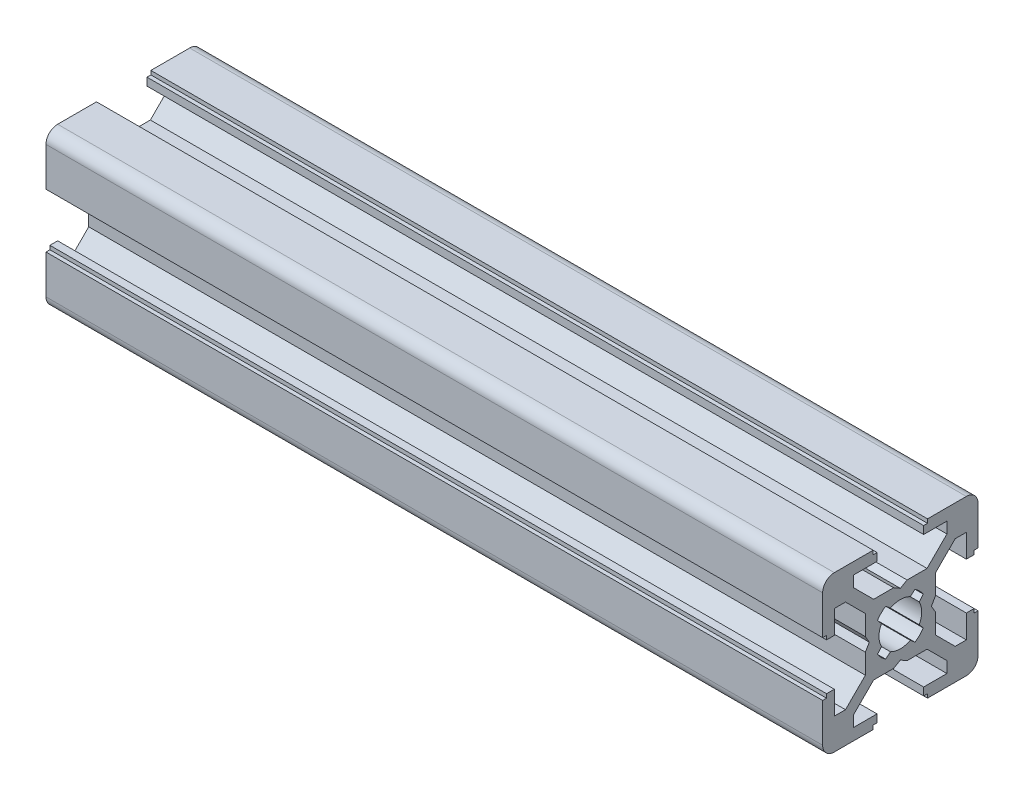
from build123d import *

# Parameters (mm, degrees)
BOSS_EXTRUDE1_DEPTH = 100


with BuildPart() as part:
    # Sketch1 → Boss-Extrude1 (new body)
    with BuildSketch(Plane(origin=(100, 0, 0), x_dir=(0, 0, -1), z_dir=(1, 0, 0))):
        with BuildLine():
            Line((7.06066017, -5.99999999), (4.5, -3.43933982))
            Line((4.5, -3.43933982), (4.5, -0.8660254))
            Line((4.5, -0.8660254), (4.000000002, -1e-09))
            Line((4.000000002, -1e-09), (4.5, 0.8660254))
            Line((4.5, 0.8660254), (4.5, 3.43933982))
            Line((4.5, 3.43933982), (7.06066017, 5.99999999))
            Line((7.06066017, 5.99999999), (8.5, 5.99999999))
            Line((8.5, 5.99999999), (8.5, 2.99999999))
            Line((8.5, 2.99999999), (9.5, 2.99999999))
            Line((9.5, 2.99999999), (9.5, 3.49999999))
            Line((9.5, 3.49999999), (10, 3.49999999))
            Line((10, 3.49999999), (10, 8.49999999))
            ThreePointArc((10, 8.49999999), (9.560660172, 9.560660162), (8.5, 9.99999999))
            Line((8.5, 9.99999999), (3.5, 9.99999999))
            Line((3.5, 9.99999999), (3.5, 9.49999999))
            Line((3.5, 9.49999999), (3, 9.49999999))
            Line((3, 9.49999999), (3, 8.49999999))
            Line((3, 8.49999999), (6, 8.49999999))
            Line((6, 8.49999999), (6, 7.06066016))
            Line((6, 7.06066016), (3.43933983, 4.49999999))
            Line((3.43933983, 4.49999999), (0.86602541, 4.49999999))
            Line((0.86602541, 4.49999999), (1.1e-08, 3.999999992))
            Line((1.1e-08, 3.999999992), (-0.86602539, 4.49999999))
            Line((-0.86602539, 4.49999999), (-3.43933981, 4.49999999))
            Line((-3.43933981, 4.49999999), (-5.99999998, 7.06066016))
            Line((-5.99999998, 7.06066016), (-5.99999998, 8.49999999))
            Line((-5.99999998, 8.49999999), (-2.99999998, 8.49999999))
            Line((-2.99999998, 8.49999999), (-2.99999998, 9.49999999))
            Line((-2.99999998, 9.49999999), (-3.49999998, 9.49999999))
            Line((-3.49999998, 9.49999999), (-3.49999998, 9.99999999))
            Line((-3.49999998, 9.99999999), (-8.49999998, 9.99999999))
            ThreePointArc((-8.49999998, 9.99999999), (-9.560660152, 9.560660162), (-9.99999998, 8.49999999))
            Line((-9.99999998, 8.49999999), (-9.99999998, 3.49999999))
            Line((-9.99999998, 3.49999999), (-9.49999998, 3.49999999))
            Line((-9.49999998, 3.49999999), (-9.49999998, 2.99999999))
            Line((-9.49999998, 2.99999999), (-8.49999998, 2.99999999))
            Line((-8.49999998, 2.99999999), (-8.49999998, 5.99999999))
            Line((-8.49999998, 5.99999999), (-7.06066015, 5.99999999))
            Line((-7.06066015, 5.99999999), (-4.49999998, 3.43933982))
            Line((-4.49999998, 3.43933982), (-4.49999998, 0.8660254))
            Line((-4.49999998, 0.8660254), (-3.999999982, -1e-09))
            Line((-3.999999982, -1e-09), (-4.49999998, -0.8660254))
            Line((-4.49999998, -0.8660254), (-4.49999998, -3.43933982))
            Line((-4.49999998, -3.43933982), (-7.06066015, -5.99999999))
            Line((-7.06066015, -5.99999999), (-8.49999998, -5.99999999))
            Line((-8.49999998, -5.99999999), (-8.49999998, -2.99999999))
            Line((-8.49999998, -2.99999999), (-9.49999998, -2.99999999))
            Line((-9.49999998, -2.99999999), (-9.49999998, -3.49999999))
            Line((-9.49999998, -3.49999999), (-9.99999998, -3.49999999))
            Line((-9.99999998, -3.49999999), (-9.99999998, -8.49999999))
            ThreePointArc((-9.99999998, -8.49999999), (-9.560660152, -9.560660162), (-8.49999998, -9.99999999))
            Line((-8.49999998, -9.99999999), (-3.49999998, -9.99999999))
            Line((-3.49999998, -9.99999999), (-3.49999998, -9.49999999))
            Line((-3.49999998, -9.49999999), (-2.99999998, -9.49999999))
            Line((-2.99999998, -9.49999999), (-2.99999998, -8.49999999))
            Line((-2.99999998, -8.49999999), (-5.99999998, -8.49999999))
            Line((-5.99999998, -8.49999999), (-5.99999998, -7.06066016))
            Line((-5.99999998, -7.06066016), (-3.43933981, -4.49999999))
            Line((-3.43933981, -4.49999999), (-0.86602539, -4.49999999))
            Line((-0.86602539, -4.49999999), (1.1e-08, -3.999999992))
            Line((1.1e-08, -3.999999992), (0.86602541, -4.49999999))
            Line((0.86602541, -4.49999999), (3.43933983, -4.49999999))
            Line((3.43933983, -4.49999999), (6, -7.06066016))
            Line((6, -7.06066016), (6, -8.49999999))
            Line((6, -8.49999999), (3, -8.49999999))
            Line((3, -8.49999999), (3, -9.49999999))
            Line((3, -9.49999999), (3.5, -9.49999999))
            Line((3.5, -9.49999999), (3.5, -9.99999999))
            Line((3.5, -9.99999999), (8.5, -9.99999999))
            ThreePointArc((8.5, -9.99999999), (9.560660172, -9.560660162), (10, -8.49999999))
            Line((10, -8.49999999), (10, -3.49999999))
            Line((10, -3.49999999), (9.5, -3.49999999))
            Line((9.5, -3.49999999), (9.5, -2.99999999))
            Line((9.5, -2.99999999), (8.5, -2.99999999))
            Line((8.5, -2.99999999), (8.5, -5.99999999))
            Line((8.5, -5.99999999), (7.06066017, -5.99999999))
        make_face()
        with BuildLine():
            Line((2.947757464, 1.886988592), (2.435674066, 1.276711353))
            ThreePointArc((2.435674066, 1.276711353), (2.750000006, 0), (2.435674066, -1.276711353))
            Line((2.435674066, -1.276711353), (2.947757463, -1.886988593))
            ThreePointArc((2.947757463, -1.886988593), (2.474929377, -2.474818092), (1.88712114, -2.94767261))
            Line((1.88712114, -2.94767261), (1.27685518, -2.43559867))
            ThreePointArc((1.27685518, -2.43559867), (0, -2.750000006), (-1.27685518, -2.43559867))
            Line((-1.27685518, -2.43559867), (-1.887121139, -2.947672611))
            ThreePointArc((-1.887121139, -2.947672611), (-2.474929377, -2.474818092), (-2.947757464, -1.886988592))
            Line((-2.947757464, -1.886988592), (-2.435674066, -1.276711353))
            ThreePointArc((-2.435674066, -1.276711353), (-2.750000006, 0), (-2.435674066, 1.276711353))
            Line((-2.435674066, 1.276711353), (-2.947757463, 1.886988593))
            ThreePointArc((-2.947757463, 1.886988593), (-2.474929377, 2.474818092), (-1.88712114, 2.94767261))
            Line((-1.88712114, 2.94767261), (-1.27685518, 2.43559867))
            ThreePointArc((-1.27685518, 2.43559867), (0, 2.750000006), (1.27685518, 2.43559867))
            Line((1.27685518, 2.43559867), (1.887121139, 2.947672611))
            ThreePointArc((1.887121139, 2.947672611), (2.474929377, 2.474818092), (2.947757464, 1.886988592))
        make_face(mode=Mode.SUBTRACT)
    extrude(amount=-BOSS_EXTRUDE1_DEPTH)


solid = part.part
